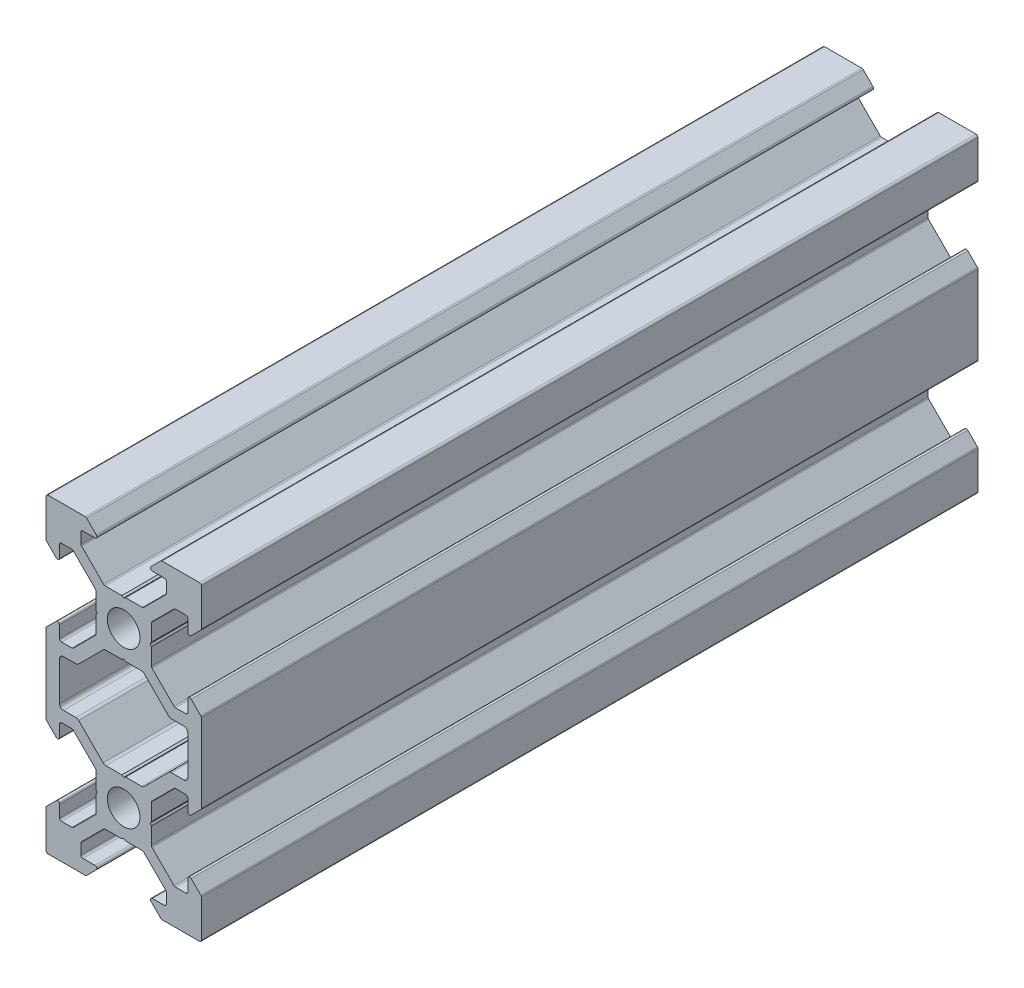
from build123d import *

# Parameters (mm, degrees)
SKETCH1_R           = 2.1
BOSS_EXTRUDE1_DEPTH = 100
FILLET1_R           = 0.25
FILLET2_R           = 0.5
CUT_EXTRUDE1_DEPTH  = 101


with BuildPart() as part:
    # Sketch1 → Boss-Extrude1 (new body)
    with BuildSketch(Plane.XY):
        Polygon((3.560660172, -2.5), (3.560660172, 2.5), (6.560660172, 5.5), (8.252142372, 5.5), (8.252142372, 3.1), (10, 4.847857628), (10, 10), (4.847857628, 10), (3.1, 8.252142372), (5.5, 8.252142372), (5.5, 6.560660172), (2.5, 3.560660172), (-2.5, 3.560660172), (-5.5, 6.560660172), (-5.5, 8.252142372), (-3.1, 8.252142372), (-4.847857628, 10), (-10, 10), (-10, 4.847857628), (-8.252142372, 3.1), (-8.252142372, 5.5), (-6.560660172, 5.5), (-3.560660172, 2.5), (-3.560660172, -2.5), (-6.560660172, -5.5), (-8.252142372, -5.5), (-8.252142372, -3.1), (-10, -4.847857628), (-10, -7), (-10, -13), (-10, -15.152142372), (-8.252142372, -16.9), (-8.252142372, -14.5), (-6.560660172, -14.5), (-3.560660172, -17.5), (-3.560660172, -22.5), (-6.560660172, -25.5), (-8.252142372, -25.5), (-8.252142372, -23.1), (-10, -24.847857628), (-10, -30), (-4.847857628, -30), (-3.1, -28.252142372), (-5.5, -28.252142372), (-5.5, -26.560660172), (-2.5, -23.560660172), (2.5, -23.560660172), (5.5, -26.560660172), (5.5, -28.252142372), (3.1, -28.252142372), (4.847857628, -30), (10, -30), (10, -24.847857628), (8.252142372, -23.1), (8.252142372, -25.5), (6.560660172, -25.5), (3.560660172, -22.5), (3.560660172, -17.5), (6.560660172, -14.5), (8.252142372, -14.5), (8.252142372, -16.9), (10, -15.152142372), (10, -13), (10, -7), (10, -4.847857628), (8.252142372, -3.1), (8.252142372, -5.5), (6.560660172, -5.5), align=None)
        Circle(SKETCH1_R, mode=Mode.SUBTRACT)
        with Locations((0, -20)):
            Circle(SKETCH1_R, mode=Mode.SUBTRACT)
        Polygon((2.5, -3.560660172), (-2.5, -3.560660172), (-5.5, -6.560660172), (-5.939339828, -7), (-8.252142372, -7), (-8.252142372, -13), (-5.939339828, -13), (-5.5, -13.439339828), (-2.5, -16.439339828), (2.5, -16.439339828), (5.5, -13.439339828), (5.939339828, -13), (8.252142372, -13), (8.252142372, -7), (5.939339828, -7), (5.5, -6.560660172), align=None, mode=Mode.SUBTRACT)
    extrude(amount=BOSS_EXTRUDE1_DEPTH)

    # Fillet1
    fillet1_edges = [part.edges().sort_by_distance(p)[0] for p in [
        (5.5, 6.560660172, 50),
        (5.5, 8.252142372, 50),
        (3.1, 8.252142372, 50),
        (4.847857628, 10, 50),
        (10, 10, 50),
        (10, 4.847857628, 50),
        (8.252142372, 3.1, 50),
        (8.252142372, 5.5, 50),
        (6.560660172, 5.5, 50),
        (3.560660172, 2.5, 50),
        (3.560660172, -2.5, 50),
        (6.560660172, -5.5, 50),
        (8.252142372, -5.5, 50),
        (8.252142372, -3.1, 50),
        (10, -4.847857628, 50),
        (10, -15.152142372, 50),
        (8.252142372, -16.9, 50),
        (8.252142372, -14.5, 50),
        (6.560660172, -14.5, 50),
        (3.560660172, -17.5, 50),
        (3.560660172, -22.5, 50),
        (6.560660172, -25.5, 50),
        (8.252142372, -25.5, 50),
        (8.252142372, -23.1, 50),
        (10, -24.847857628, 50),
        (10, -30, 50),
        (4.847857628, -30, 50),
        (3.1, -28.252142372, 50),
        (5.5, -28.252142372, 50),
        (5.5, -26.560660172, 50),
        (2.5, -23.560660172, 50),
        (-2.5, -23.560660172, 50),
        (-5.5, -26.560660172, 50),
        (-5.5, -28.252142372, 50),
        (-3.1, -28.252142372, 50),
        (-4.847857628, -30, 50),
        (-10, -30, 50),
        (-10, -24.847857628, 50),
        (-8.252142372, -23.1, 50),
        (-8.252142372, -25.5, 50),
        (-6.560660172, -25.5, 50),
        (-3.560660172, -22.5, 50),
        (-3.560660172, -17.5, 50),
        (-6.560660172, -14.5, 50),
        (-8.252142372, -14.5, 50),
        (-8.252142372, -16.9, 50),
        (-10, -15.152142372, 50),
        (-10, -4.847857628, 50),
        (-8.252142372, -3.1, 50),
        (-8.252142372, -5.5, 50),
        (-6.560660172, -5.5, 50),
        (-3.560660172, -2.5, 50),
        (-3.560660172, 2.5, 50),
        (-6.560660172, 5.5, 50),
        (-8.252142372, 5.5, 50),
        (-8.252142372, 3.1, 50),
        (-10, 4.847857628, 50),
        (-10, 10, 50),
        (-4.847857628, 10, 50),
        (-3.1, 8.252142372, 50),
        (-5.5, 8.252142372, 50),
        (-5.5, 6.560660172, 50),
        (-2.5, 3.560660172, 50),
        (2.5, 3.560660172, 50),
    ]]
    fillet(fillet1_edges, radius=FILLET1_R)

    # Fillet2
    fillet2_edges = [part.edges().sort_by_distance(p)[0] for p in [
        (-2.5, -3.560660172, 50),
        (-5.939339828, -7, 50),
        (-8.252142372, -7, 50),
        (-8.252142372, -13, 50),
        (-5.939339828, -13, 50),
        (-2.5, -16.439339828, 50),
        (2.5, -16.439339828, 50),
        (5.939339828, -13, 50),
        (8.252142372, -13, 50),
        (8.252142372, -7, 50),
        (5.939339828, -7, 50),
        (2.5, -3.560660172, 50),
    ]]
    fillet(fillet2_edges, radius=FILLET2_R)

    # Sketch2 → Cut-Extrude1 (cut, through all)
    with BuildSketch(Plane.XY.offset(100)):
        Polygon((0, 3.398953432), (-0.242280927, 3.560660172), (0.242280927, 3.560660172), align=None)
        Polygon((0, -3.398953432), (0.242280927, -3.560660172), (-0.242280927, -3.560660172), align=None)
        Polygon((3.560660172, 0.242280927), (3.560660172, -0.242280927), (3.398953432, 0), align=None)
        Polygon((-3.560660172, 0.242280927), (-3.560660172, -0.242280927), (-3.398953432, 0), align=None)
        Polygon((-3.398953432, -20), (-3.560660172, -20.242280927), (-3.560660172, -19.757719073), align=None)
        Polygon((3.398953432, -20), (3.560660172, -19.757719073), (3.560660172, -20.242280927), align=None)
        Polygon((-0.242280927, -16.439339828), (0.242280927, -16.439339828), (0, -16.601046568), align=None)
        Polygon((-0.242280927, -23.560660172), (0.242280927, -23.560660172), (0, -23.398953432), align=None)
    extrude(amount=-CUT_EXTRUDE1_DEPTH, mode=Mode.SUBTRACT)


solid = part.part
